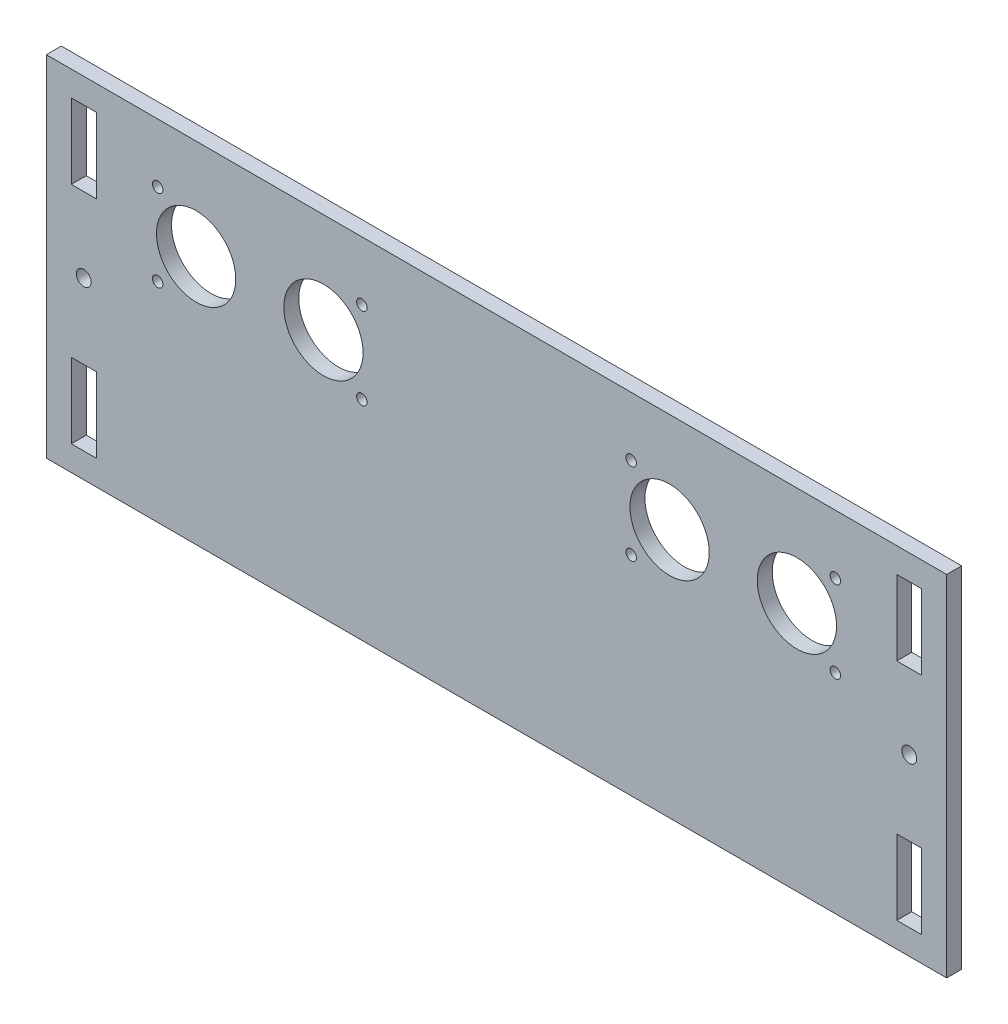
from build123d import *

# Parameters (mm, degrees)
SCHIZZO1_W                   = 180.34
SCHIZZO1_H                   = 70
ESTRUSIONE_ESTRUSIONE1_DEPTH = 3
SCHIZZO2_R                   = 1.5
SCHIZZO2_W                   = 5
SCHIZZO2_H                   = 15
TAGLIO_ESTRUSIONE1_DEPTH     = 4
SCHIZZO3_R                   = 7.94
SCHIZZO3_R_2                 = 1.05
TAGLIO_ESTRUSIONE2_DEPTH     = 4


with BuildPart() as part:
    # Schizzo1 → Estrusione-Estrusione1 (new body)
    with BuildSketch(Plane.XY):
        Rectangle(SCHIZZO1_W, SCHIZZO1_H)
    extrude(amount=ESTRUSIONE_ESTRUSIONE1_DEPTH)

    # Schizzo2 → Taglio-Estrusione1 (cut, through all)
    with BuildSketch(Plane.XY):
        with Locations((-82.67, 0)):
            Circle(SCHIZZO2_R)
        with Locations((82.67, 0)):
            Circle(SCHIZZO2_R)
        with Locations((-82.67, 22.5)):
            Rectangle(SCHIZZO2_W, SCHIZZO2_H)
        with Locations((-82.67, -22.5)):
            Rectangle(SCHIZZO2_W, SCHIZZO2_H)
        with Locations((82.67, 22.5)):
            Rectangle(SCHIZZO2_W, SCHIZZO2_H)
        with Locations((82.67, -22.5)):
            Rectangle(SCHIZZO2_W, SCHIZZO2_H)
    extrude(amount=TAGLIO_ESTRUSIONE1_DEPTH, mode=Mode.SUBTRACT)

    # Schizzo3 → Taglio-Estrusione2 (cut, through all)
    with BuildSketch(Plane.XY):
        with Locations((-60.17, 15)):
            Circle(SCHIZZO3_R)
        with Locations((-34.67, 15)):
            Circle(SCHIZZO3_R)
        with Locations((60.17, 15)):
            Circle(SCHIZZO3_R)
        with Locations((34.67, 15)):
            Circle(SCHIZZO3_R)
        with Locations((-26.97, 6.8)):
            Circle(SCHIZZO3_R_2)
        with Locations((-26.97, 23.2)):
            Circle(SCHIZZO3_R_2)
        with Locations((-67.87, 6.8)):
            Circle(SCHIZZO3_R_2)
        with Locations((-67.87, 23.2)):
            Circle(SCHIZZO3_R_2)
        with Locations((26.97, 23.2)):
            Circle(SCHIZZO3_R_2)
        with Locations((26.97, 6.8)):
            Circle(SCHIZZO3_R_2)
        with Locations((67.87, 6.8)):
            Circle(SCHIZZO3_R_2)
        with Locations((67.87, 23.2)):
            Circle(SCHIZZO3_R_2)
    extrude(amount=TAGLIO_ESTRUSIONE2_DEPTH, mode=Mode.SUBTRACT)


solid = part.part
